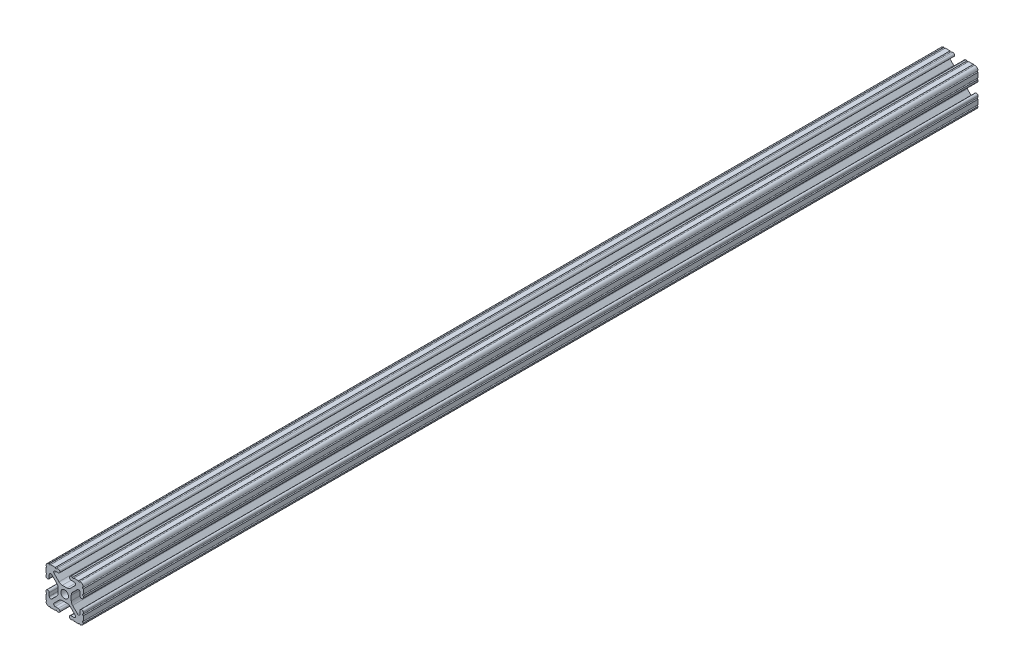
from build123d import *

# Parameters (mm, degrees)
SKETCH1_R           = 2.6035
BOSS_EXTRUDE1_DEPTH = 609.6


with BuildPart() as part:
    # Sketch1 → Boss-Extrude1 (new body)
    with BuildSketch(Plane(origin=(0, 0, -304.8), x_dir=(-1, 0, 0), z_dir=(0, 0, -1))):
        with BuildLine():
            Line((12.7, -9.5504), (12.7, -6.3330836))
            ThreePointArc((12.7, -6.3330836), (12.192, -5.8250836), (12.7, -5.3170836))
            Line((12.7, -5.3170836), (12.7, -4.3434))
            ThreePointArc((12.7, -4.3434), (11.5951, -3.2385), (10.4902, -4.3434))
            Line((10.4902, -4.3434), (10.4902, -6.474794456))
            ThreePointArc((10.4902, -6.474794456), (9.863006367, -7.413456061), (8.75577951, -7.193214945))
            Line((8.75577951, -7.193214945), (5.42573597, -3.863171405))
            ThreePointArc((5.42573597, -3.863171405), (4.737482484, -2.833127272), (4.4958, -1.618107374))
            Line((4.4958, -1.618107374), (4.4958, 1.618107374))
            ThreePointArc((4.4958, 1.618107374), (4.737482484, 2.833127272), (5.42573597, 3.863171405))
            Line((5.42573597, 3.863171405), (8.75577951, 7.193214945))
            ThreePointArc((8.75577951, 7.193214945), (9.863006367, 7.413456061), (10.4902, 6.474794456))
            Line((10.4902, 6.474794456), (10.4902, 4.343399971))
            ThreePointArc((10.4902, 4.343399971), (11.5951, 3.238499971), (12.7, 4.343399971))
            Line((12.7, 4.343399971), (12.7, 5.3170836))
            ThreePointArc((12.7, 5.3170836), (12.192, 5.8250836), (12.7, 6.3330836))
            Line((12.7, 6.3330836), (12.7, 9.5504))
            ThreePointArc((12.7, 9.5504), (12.192000006, 10.058323491), (12.699846982, 10.566399977))
            ThreePointArc((12.699846982, 10.566399977), (12.082522516, 12.082522516), (10.566399977, 12.699846982))
            ThreePointArc((10.566399977, 12.699846982), (10.058323491, 12.192000006), (9.5504, 12.7))
            Line((9.5504, 12.7), (6.3330836, 12.7))
            ThreePointArc((6.3330836, 12.7), (5.8250836, 12.192), (5.3170836, 12.7))
            Line((5.3170836, 12.7), (4.3434, 12.7))
            ThreePointArc((4.3434, 12.7), (3.2385, 11.5951), (4.3434, 10.4902))
            Line((4.3434, 10.4902), (6.474794456, 10.4902))
            ThreePointArc((6.474794456, 10.4902), (7.413456061, 9.863006367), (7.193214945, 8.75577951))
            Line((7.193214945, 8.75577951), (3.863171405, 5.42573597))
            ThreePointArc((3.863171405, 5.42573597), (2.833127272, 4.737482484), (1.618107374, 4.4958))
            Line((1.618107374, 4.4958), (-1.618107374, 4.4958))
            ThreePointArc((-1.618107374, 4.4958), (-2.833127272, 4.737482484), (-3.863171405, 5.42573597))
            Line((-3.863171405, 5.42573597), (-7.193214945, 8.75577951))
            ThreePointArc((-7.193214945, 8.75577951), (-7.413456061, 9.863006367), (-6.474794456, 10.4902))
            Line((-6.474794456, 10.4902), (-4.343399971, 10.4902))
            ThreePointArc((-4.343399971, 10.4902), (-3.238499971, 11.5951), (-4.343399971, 12.7))
            Line((-4.343399971, 12.7), (-5.3170836, 12.7))
            ThreePointArc((-5.3170836, 12.7), (-5.8250836, 12.192), (-6.3330836, 12.7))
            Line((-6.3330836, 12.7), (-9.5504, 12.7))
            ThreePointArc((-9.5504, 12.7), (-10.058323491, 12.192000006), (-10.566399977, 12.699846982))
            ThreePointArc((-10.566399977, 12.699846982), (-12.082522516, 12.082522516), (-12.699846982, 10.566399977))
            ThreePointArc((-12.699846982, 10.566399977), (-12.192000006, 10.058323491), (-12.7, 9.5504))
            Line((-12.7, 9.5504), (-12.7, 6.3330836))
            ThreePointArc((-12.7, 6.3330836), (-12.192, 5.8250836), (-12.7, 5.3170836))
            Line((-12.7, 5.3170836), (-12.7, 4.3434))
            ThreePointArc((-12.7, 4.3434), (-11.5951, 3.2385), (-10.4902, 4.3434))
            Line((-10.4902, 4.3434), (-10.4902, 6.474794456))
            ThreePointArc((-10.4902, 6.474794456), (-9.863006367, 7.413456061), (-8.75577951, 7.193214945))
            Line((-8.75577951, 7.193214945), (-5.42573597, 3.863171405))
            ThreePointArc((-5.42573597, 3.863171405), (-4.737482484, 2.833127272), (-4.4958, 1.618107374))
            Line((-4.4958, 1.618107374), (-4.4958, -1.618107374))
            ThreePointArc((-4.4958, -1.618107374), (-4.737482484, -2.833127272), (-5.42573597, -3.863171405))
            Line((-5.42573597, -3.863171405), (-8.75577951, -7.193214945))
            ThreePointArc((-8.75577951, -7.193214945), (-9.863006367, -7.413456061), (-10.4902, -6.474794456))
            Line((-10.4902, -6.474794456), (-10.4902, -4.343399971))
            ThreePointArc((-10.4902, -4.343399971), (-11.5951, -3.238499971), (-12.7, -4.343399971))
            Line((-12.7, -4.343399971), (-12.7, -5.3170836))
            ThreePointArc((-12.7, -5.3170836), (-12.192, -5.8250836), (-12.7, -6.3330836))
            Line((-12.7, -6.3330836), (-12.7, -9.5504))
            ThreePointArc((-12.7, -9.5504), (-12.192000006, -10.058323491), (-12.699846982, -10.566399977))
            ThreePointArc((-12.699846982, -10.566399977), (-12.082522516, -12.082522516), (-10.566399977, -12.699846982))
            ThreePointArc((-10.566399977, -12.699846982), (-10.058323491, -12.192000006), (-9.5504, -12.7))
            Line((-9.5504, -12.7), (-6.3330836, -12.7))
            ThreePointArc((-6.3330836, -12.7), (-5.8250836, -12.192), (-5.3170836, -12.7))
            Line((-5.3170836, -12.7), (-4.3434, -12.7))
            ThreePointArc((-4.3434, -12.7), (-3.2385, -11.5951), (-4.3434, -10.4902))
            Line((-4.3434, -10.4902), (-6.474794456, -10.4902))
            ThreePointArc((-6.474794456, -10.4902), (-7.413456061, -9.863006367), (-7.193214945, -8.75577951))
            Line((-7.193214945, -8.75577951), (-3.863171405, -5.42573597))
            ThreePointArc((-3.863171405, -5.42573597), (-2.833127272, -4.737482484), (-1.618107374, -4.4958))
            Line((-1.618107374, -4.4958), (1.618107374, -4.4958))
            ThreePointArc((1.618107374, -4.4958), (2.833127272, -4.737482484), (3.863171405, -5.42573597))
            Line((3.863171405, -5.42573597), (7.193214945, -8.75577951))
            ThreePointArc((7.193214945, -8.75577951), (7.413456061, -9.863006367), (6.474794456, -10.4902))
            Line((6.474794456, -10.4902), (4.343399971, -10.4902))
            ThreePointArc((4.343399971, -10.4902), (3.238499971, -11.5951), (4.343399971, -12.7))
            Line((4.343399971, -12.7), (5.3170836, -12.7))
            ThreePointArc((5.3170836, -12.7), (5.8250836, -12.192), (6.3330836, -12.7))
            Line((6.3330836, -12.7), (9.5504, -12.7))
            ThreePointArc((9.5504, -12.7), (10.058323491, -12.192000006), (10.566399977, -12.699846982))
            ThreePointArc((10.566399977, -12.699846982), (12.082522516, -12.082522516), (12.699846982, -10.566399977))
            ThreePointArc((12.699846982, -10.566399977), (12.192000006, -10.058323491), (12.7, -9.5504))
        make_face()
        Circle(SKETCH1_R, mode=Mode.SUBTRACT)
    extrude(amount=-BOSS_EXTRUDE1_DEPTH)


solid = part.part
